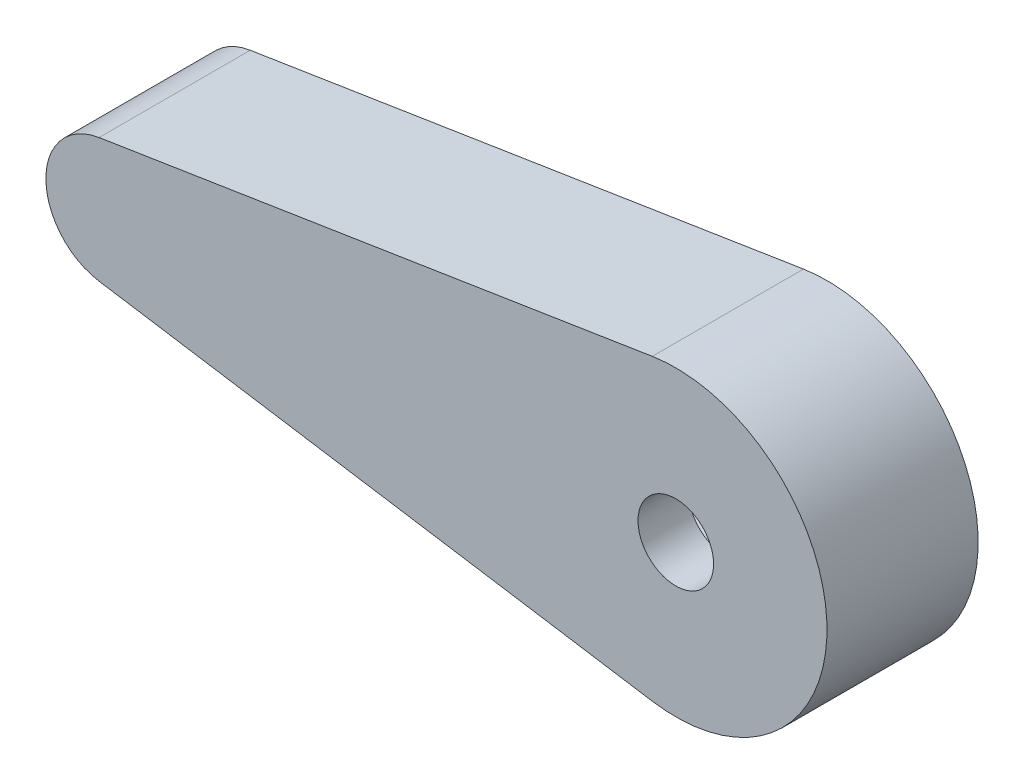
from build123d import *
from build123d.topology import SkipClean

# Parameters (mm, degrees)
BOSS_EXTRUDE1_DEPTH = 2
BOSS_EXTRUDE2_START = 4
BOSS_EXTRUDE2_DEPTH = 4
SKETCH3_R           = 1.5
CUT_EXTRUDE1_DEPTH  = 27.019223663


with BuildPart() as part:
    # Sketch1 → Boss-Extrude1 (new body)
    with BuildSketch(Plane.XY):
        with BuildLine():
            Line((-22.888888889, -2.469567863), (-0.933333333, -5.926962872))
            ThreePointArc((-0.933333333, -5.926962872), (6, 0), (-0.933333333, 5.926962872))
            Line((-0.933333333, 5.926962872), (-22.888888889, 2.469567863))
            ThreePointArc((-22.888888889, 2.469567863), (-25, 0), (-22.888888889, -2.469567863))
        make_face()
    extrude(amount=BOSS_EXTRUDE1_DEPTH)

    # Sketch2 → Boss-Extrude2 (add)
    with SkipClean():  # the faces are left unmerged after this step: merging them gives an invalid solid
        with BuildSketch(Plane(origin=(0, 0, 0), x_dir=(-1, 0, 0), z_dir=(0, 0, -1)).offset(BOSS_EXTRUDE2_START)):
            with BuildLine():
                Line((22.888888889, 2.469567863), (0.933333333, 5.926962872))
                ThreePointArc((0.933333333, 5.926962872), (-6, 0), (0.933333333, -5.926962872))
                Line((0.933333333, -5.926962872), (22.888888889, -2.469567863))
                ThreePointArc((22.888888889, -2.469567863), (25, 0), (22.888888889, 2.469567863))
            make_face()
            with BuildLine():
                Line((14.175490262, 2.296574012), (2.322474144, 2.944250983))
                ThreePointArc((2.322474144, 2.944250983), (-3.75, 0), (2.322474144, -2.944250983))
                Line((2.322474144, -2.944250983), (14.175490262, -2.296574012))
                ThreePointArc((14.175490262, -2.296574012), (16.35, 0), (14.175490262, 2.296574012))
            make_face(mode=Mode.SUBTRACT)
        extrude(amount=-BOSS_EXTRUDE2_DEPTH)

    # Sketch3 → Cut-Extrude1 (cut, through all)
    with SkipClean():  # the faces are left unmerged after this step: merging them gives an invalid solid
        with BuildSketch(Plane(origin=(0, 0, 0), x_dir=(-1, 0, 0), z_dir=(0, 0, -1))):
            Circle(SKETCH3_R)
        extrude(amount=-CUT_EXTRUDE1_DEPTH, mode=Mode.SUBTRACT)


solid = part.part
